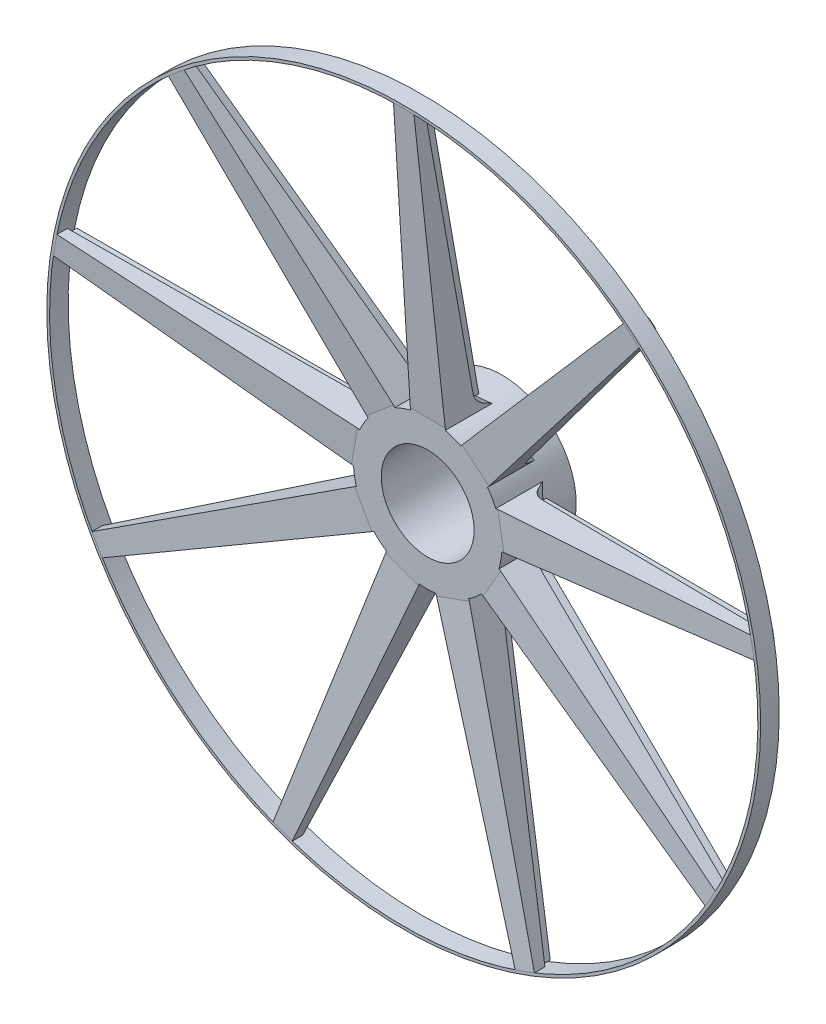
from build123d import *

# Parameters (mm, degrees)
SKETCH1_R                = 40
SKETCH1_R_2              = 25
BOSS_EXTRUDE1_DEPTH      = 40
BOSS_EXTRUDE2_DEPTH      = 9.5
BOSS_EXTRUDE2_DEPTH_BACK = 9.5
BOSS_EXTRUDE3_START      = -25
BOSS_EXTRUDE3_DEPTH      = 25
BOSS_EXTRUDE4_DEPTH      = 19
CUT_EXTRUDE3_DEPTH       = 7
CUT_EXTRUDE6_DEPTH       = 202.951401835
CIRPATTERN11_COUNT       = 9
SKETCH21_R               = 192.25
SKETCH21_R_2             = 190.75
BOSS_EXTRUDE5_DEPTH      = 10


with BuildPart() as part:
    # Sketch1 → Boss-Extrude1 (new body)
    with BuildSketch(Plane.XY):
        Circle(SKETCH1_R)
        Circle(SKETCH1_R_2, mode=Mode.SUBTRACT)
    extrude(amount=BOSS_EXTRUDE1_DEPTH)



with BuildPart() as body_2:
    # Sketch4 → Boss-Extrude2 (new, two sides: drawn at the far end of the back side and taken through both)
    with BuildSketch(Plane(origin=(0, 0, 0), x_dir=(0, 0, -1), z_dir=(1, 0, 0)).offset(-BOSS_EXTRUDE2_DEPTH_BACK)):
        Polygon((-40, 40), (-15, 40), (-41.581292342, 190.75), (-52.903744697, 190.75), align=None)
    extrude(amount=BOSS_EXTRUDE2_DEPTH + BOSS_EXTRUDE2_DEPTH_BACK)


with BuildPart() as part_1:
    add(part.part)

    add(body_2.part)  # Boss-Extrude3 merges body 2
    # Sketch6 → Boss-Extrude3 (add)
    with BuildSketch(Plane.XY.offset(40).offset(BOSS_EXTRUDE3_START)):
        with BuildLine():
            Line((-5e-09, 40), (-9.5, 40))
            Line((-9.5, 40), (-9.5, 38.855501541))
            ThreePointArc((-9.5, 38.855501541), (-4.784346267, 39.712844658), (-5e-09, 40))
        make_face()
        with BuildLine():
            Line((9.5, 40), (-5e-09, 40))
            ThreePointArc((-5e-09, 40), (4.784346262, 39.712844658), (9.5, 38.855501541))
            Line((9.5, 38.855501541), (9.5, 40))
        make_face()
        with BuildLine():
            ThreePointArc((9.5, 31.080540536), (0, 32.5), (-9.5, 31.080540536))
            Line((-9.5, 31.080540536), (-9.5, 30.551163992))
            Line((-9.5, 30.551163992), (9.5, 30.551163992))
            Line((9.5, 30.551163992), (9.5, 31.080540536))
        make_face()
    extrude(amount=BOSS_EXTRUDE3_DEPTH)

    # Sketch7 → Boss-Extrude4 (add)
    with BuildSketch(Plane(origin=(9.5, 0, 0), x_dir=(0, 0, -1), z_dir=(1, 0, 0))):
        Polygon((-14.798194042, 38.855501541), (-15, 40), (-15, 38.855501541), align=None)
    extrude(amount=-BOSS_EXTRUDE4_DEPTH)

    # Sketch10 → Cut-Extrude3 (cut)
    with BuildSketch(Plane.ZY.offset(9.5)):
        with BuildLine():
            Line((47.242518519, 190.75), (24.887754344, 48.754864533))
            ThreePointArc((24.887754344, 48.754864533), (23.160857765, 44.517451094), (19.727226557, 41.492881507))
            Line((19.727226557, 41.492881507), (14.798194042, 38.855501541))
            Line((14.798194042, 38.855501541), (41.581292342, 190.75))
            Line((41.581292342, 190.75), (47.242518519, 190.75))
        make_face()
    cut_extrude3 = extrude(amount=-CUT_EXTRUDE3_DEPTH, mode=Mode.SUBTRACT)

    # Mirror1: Cut-Extrude3 across plane
    add(cut_extrude3.mirror(Plane(origin=(0, 0, 0), x_dir=(0, 0, 1), z_dir=(1, 0, 0))), mode=Mode.SUBTRACT)

    # Sketch20 → Cut-Extrude6 (cut, through all)
    with BuildSketch(Plane(origin=(0, 0, 0), x_dir=(-1, 0, 0), z_dir=(0, 0, -1))):
        Polygon((5.5, 190.75), (9.5, 33.591899875), (9.5, 190.75), align=None)
        Polygon((-5.5, 190.75), (-9.5, 38.855501541), (-9.5, 190.75), align=None)
    extrude(amount=-CUT_EXTRUDE6_DEPTH, mode=Mode.SUBTRACT)


with BuildPart() as cirpattern11_1:
    # CirPattern11: pattern copy
    add(part_1.part.rotate(Axis((0, 0, 0), (0, 0, 1)), 1 * 360 / CIRPATTERN11_COUNT))


with BuildPart() as cirpattern11_2:
    # CirPattern11: pattern copy
    add(part_1.part.rotate(Axis((0, 0, 0), (0, 0, 1)), 2 * 360 / CIRPATTERN11_COUNT))


with BuildPart() as cirpattern11_3:
    # CirPattern11: pattern copy
    add(part_1.part.rotate(Axis((0, 0, 0), (0, 0, 1)), 3 * 360 / CIRPATTERN11_COUNT))


with BuildPart() as cirpattern11_4:
    # CirPattern11: pattern copy
    add(part_1.part.rotate(Axis((0, 0, 0), (0, 0, 1)), 4 * 360 / CIRPATTERN11_COUNT))


with BuildPart() as cirpattern11_5:
    # CirPattern11: pattern copy
    add(part_1.part.rotate(Axis((0, 0, 0), (0, 0, 1)), 5 * 360 / CIRPATTERN11_COUNT))


with BuildPart() as cirpattern11_6:
    # CirPattern11: pattern copy
    add(part_1.part.rotate(Axis((0, 0, 0), (0, 0, 1)), 6 * 360 / CIRPATTERN11_COUNT))


with BuildPart() as cirpattern11_7:
    # CirPattern11: pattern copy
    add(part_1.part.rotate(Axis((0, 0, 0), (0, 0, 1)), 7 * 360 / CIRPATTERN11_COUNT))


with BuildPart() as cirpattern11_8:
    # CirPattern11: pattern copy
    add(part_1.part.rotate(Axis((0, 0, 0), (0, 0, 1)), 8 * 360 / CIRPATTERN11_COUNT))


with BuildPart() as part_2:
    add(part_1.part)

    add(cirpattern11_1.part)  # Boss-Extrude5 merges CirPattern11_1

    add(cirpattern11_2.part)  # Boss-Extrude5 merges CirPattern11_2

    add(cirpattern11_3.part)  # Boss-Extrude5 merges CirPattern11_3

    add(cirpattern11_4.part)  # Boss-Extrude5 merges CirPattern11_4

    add(cirpattern11_5.part)  # Boss-Extrude5 merges CirPattern11_5

    add(cirpattern11_6.part)  # Boss-Extrude5 merges CirPattern11_6

    add(cirpattern11_7.part)  # Boss-Extrude5 merges CirPattern11_7

    add(cirpattern11_8.part)  # Boss-Extrude5 merges CirPattern11_8
    # Sketch21 → Boss-Extrude5 (add)
    with BuildSketch(Plane(origin=(0, 0, 52.903744697), x_dir=(-1, 0, 0), z_dir=(0, 0, -1))):
        Circle(SKETCH21_R)
        Circle(SKETCH21_R_2, mode=Mode.SUBTRACT)
    extrude(amount=BOSS_EXTRUDE5_DEPTH)


solid = part_2.part
